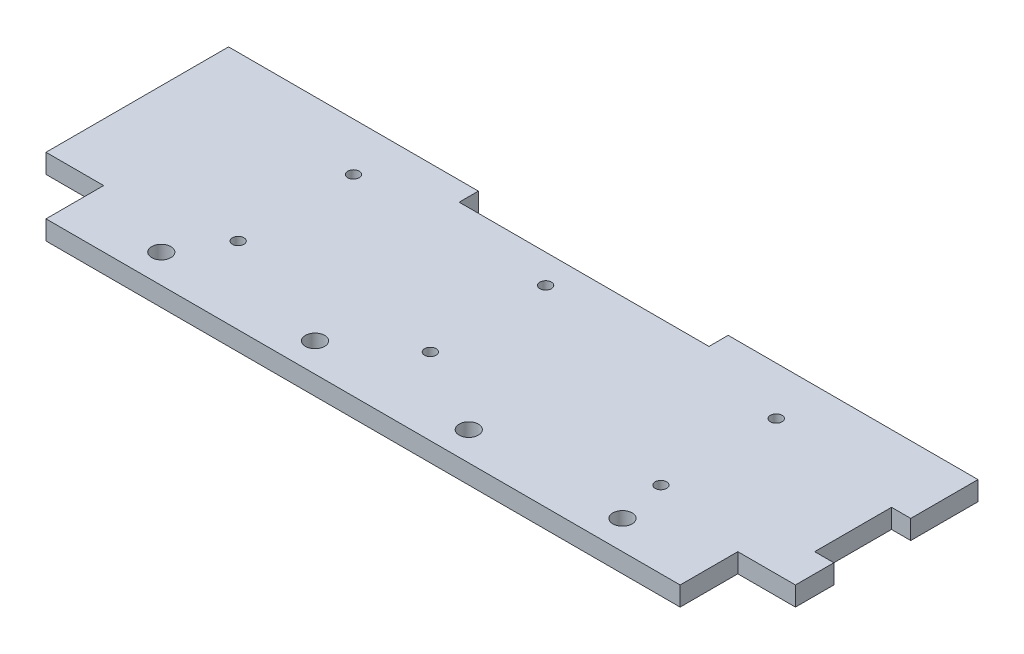
from build123d import *

# Parameters (mm, degrees)
SKETCH1_R           = 5
SKETCH1_R_2         = 3
BOSS_EXTRUDE1_DEPTH = 10
SKETCH2_W           = 30
SKETCH2_H           = 30
CUT_EXTRUDE1_DEPTH  = 10


with BuildPart() as part:
    # Sketch1 → Boss-Extrude1 (new body)
    with BuildSketch(Plane(origin=(0, 0, 0), x_dir=(1, 0, 0), z_dir=(0, 1, 0))):
        Polygon((0, 15), (-390, 15), (-390, 140), (-260, 140), (-260, 130), (-130, 130), (-130, 140), (0, 140), (0, 105), (-10, 105), (-10, 65), (0, 65), align=None)
        with Locations((-315, 30)):
            Circle(SKETCH1_R, mode=Mode.SUBTRACT)
        with Locations((-235, 30)):
            Circle(SKETCH1_R, mode=Mode.SUBTRACT)
        with Locations((-155, 30)):
            Circle(SKETCH1_R, mode=Mode.SUBTRACT)
        with Locations((-75, 30)):
            Circle(SKETCH1_R, mode=Mode.SUBTRACT)
        with Locations((-80, 55)):
            Circle(SKETCH1_R_2, mode=Mode.SUBTRACT)
        with Locations((-200, 55)):
            Circle(SKETCH1_R_2, mode=Mode.SUBTRACT)
        with Locations((-300, 55)):
            Circle(SKETCH1_R_2, mode=Mode.SUBTRACT)
        with Locations((-300, 115)):
            Circle(SKETCH1_R_2, mode=Mode.SUBTRACT)
        with Locations((-200, 115)):
            Circle(SKETCH1_R_2, mode=Mode.SUBTRACT)
        with Locations((-80, 115)):
            Circle(SKETCH1_R_2, mode=Mode.SUBTRACT)
    extrude(amount=BOSS_EXTRUDE1_DEPTH)

    # Sketch2 → Cut-Extrude1 (cut)
    with BuildSketch(Plane.XZ):
        with Locations((-15, -30)):
            Rectangle(SKETCH2_W, SKETCH2_H)
        with Locations((-375, -30)):
            Rectangle(SKETCH2_W, SKETCH2_H)
    extrude(amount=-CUT_EXTRUDE1_DEPTH, mode=Mode.SUBTRACT)


solid = part.part
